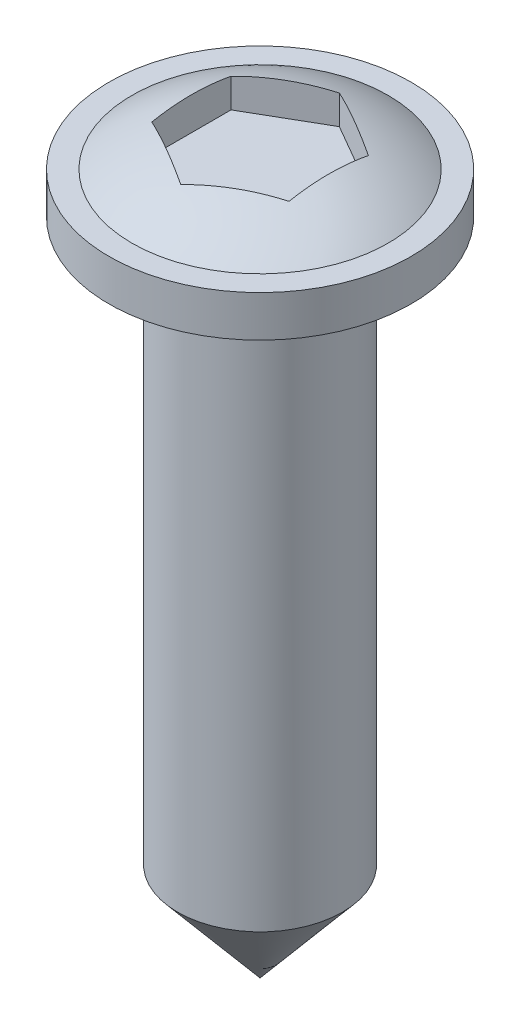
from build123d import *

# Parameters (mm, degrees)
ENL_V_MAT_EXTRU_1_DEPTH = 0.8


with BuildPart() as part:
    # Esquisse1 → Révolution1 (revolve)
    with BuildSketch(Plane.XY, mode=Mode.PRIVATE) as r_volution1_sk:
        with BuildLine():
            Line((-2.75, -1.5), (-1.5, -1.5))
            Line((-1.5, -1.5), (-1.5, -11.712369611))
            Line((-1.5, -11.712369611), (0, -13.5))
            Line((0, -13.5), (0, 0))
            ThreePointArc((0, 0), (-1.224744871, -0.192113447), (-2.331844763, -0.75))
            Line((-2.331844763, -0.75), (-2.75, -0.75))
            Line((-2.75, -0.75), (-2.75, -1.5))
        make_face()
    revolve(r_volution1_sk.sketch.rotate(Axis((0, -18.848412698, 0), (0, 1, 0)), 270), axis=Axis((0, -18.848412698, 0), (0, 1, 0)))  # turned: the seam where the file's is

    # Esquisse2 → Enlèv. mat.-Extru.1 (cut)
    with BuildSketch(Plane(origin=(0, 0, 0), x_dir=(1, 0, 0), z_dir=(0, 1, 0))):
        Polygon((0, 1.443375673), (-1.25, 0.721687836), (-1.25, -0.721687836), (0, -1.443375673), (1.25, -0.721687836), (1.25, 0.721687836), align=None)
    extrude(amount=-ENL_V_MAT_EXTRU_1_DEPTH, mode=Mode.SUBTRACT)


solid = part.part
